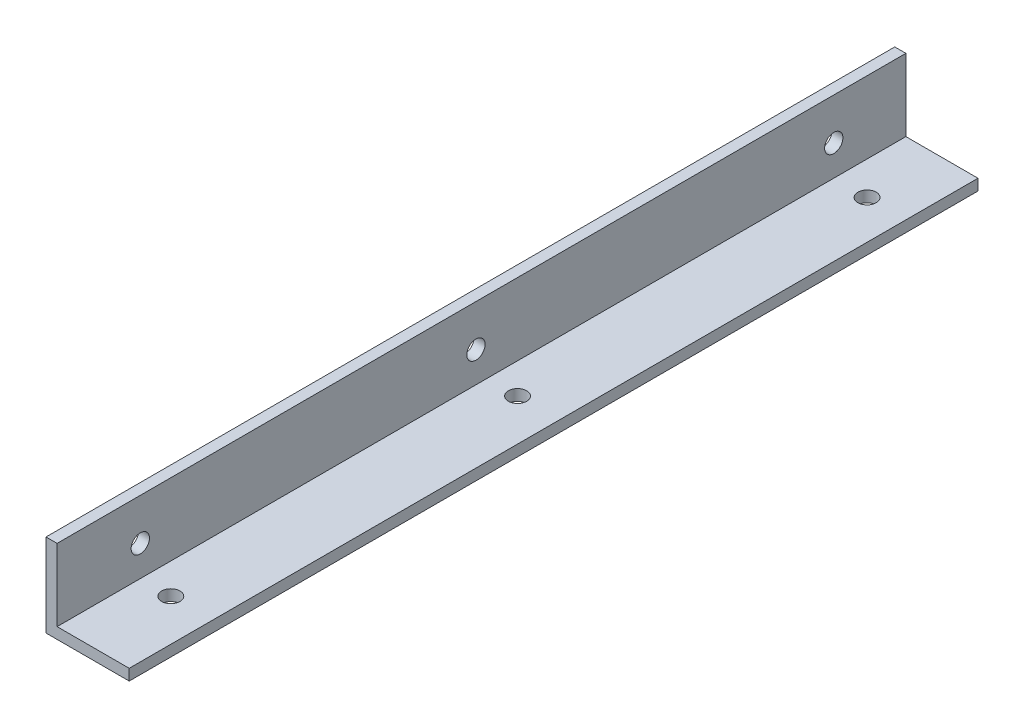
from build123d import *

# Parameters (mm, degrees)
EXTRUDE_1_DEPTH          = 155
M4X0_7_1_D               = 3.3
M4X0_7_1_DEPTH           = 11.5
M4X0_7_1_TIP             = 0.991420021
M4X0_7_1_ON_FACE_2_D     = 3.3
M4X0_7_1_ON_FACE_2_DEPTH = 11.5
M4X0_7_1_ON_FACE_2_TIP   = 0.991420021
SKETCH_6_W               = 24.634949406
SKETCH_6_H               = 34.337648086
CUT_EXTRUDE_2_DEPTH      = 2


with BuildPart() as part:
    # ｽｹｯﾁ1 → ﾎﾞｽ - 押し出し1 (new body)
    with BuildSketch(Plane.XY):
        Polygon((0, 0), (0, 15), (2, 15), (2, 2), (15, 2), (15, 0), align=None)
    extrude(amount=EXTRUDE_1_DEPTH)

    # M4x0.7 ねじ穴1
    with Locations(Plane(origin=(2, 7.5, 140), x_dir=(0, 1, 0), z_dir=(1, 0, 0))):
        with Locations((0, 0), (0, -60.5), (0, -125)):
            Hole(M4X0_7_1_D / 2, depth=M4X0_7_1_DEPTH)
            with Locations((0, 0, -(M4X0_7_1_DEPTH + M4X0_7_1_TIP / 2))):  # 118° drill point
                Cone(0, M4X0_7_1_D / 2, M4X0_7_1_TIP, mode=Mode.SUBTRACT)

    # M4x0.7 ねじ穴1 on face 2
    with Locations(Plane(origin=(7.5, 2, 140), x_dir=(0, 0, 1), z_dir=(0, 1, 0))):
        with Locations((0, 0), (-62.5, 0), (-125, 0.5)):
            Hole(M4X0_7_1_ON_FACE_2_D / 2, depth=M4X0_7_1_ON_FACE_2_DEPTH)
            with Locations((0, 0, -(M4X0_7_1_ON_FACE_2_DEPTH + M4X0_7_1_ON_FACE_2_TIP / 2))):  # 118° drill point
                Cone(0, M4X0_7_1_ON_FACE_2_D / 2, M4X0_7_1_ON_FACE_2_TIP, mode=Mode.SUBTRACT)

    # ｽｹｯﾁ6 → ｶｯﾄ - 押し出し2 (cut)
    with BuildSketch(Plane(origin=(0, 0, 0), x_dir=(-1, 0, 0), z_dir=(0, 0, -1))):
        with Locations((-5.917994617, 11.841361704)):
            Rectangle(SKETCH_6_W, SKETCH_6_H)
    extrude(amount=-CUT_EXTRUDE_2_DEPTH, mode=Mode.SUBTRACT)


solid = part.part
